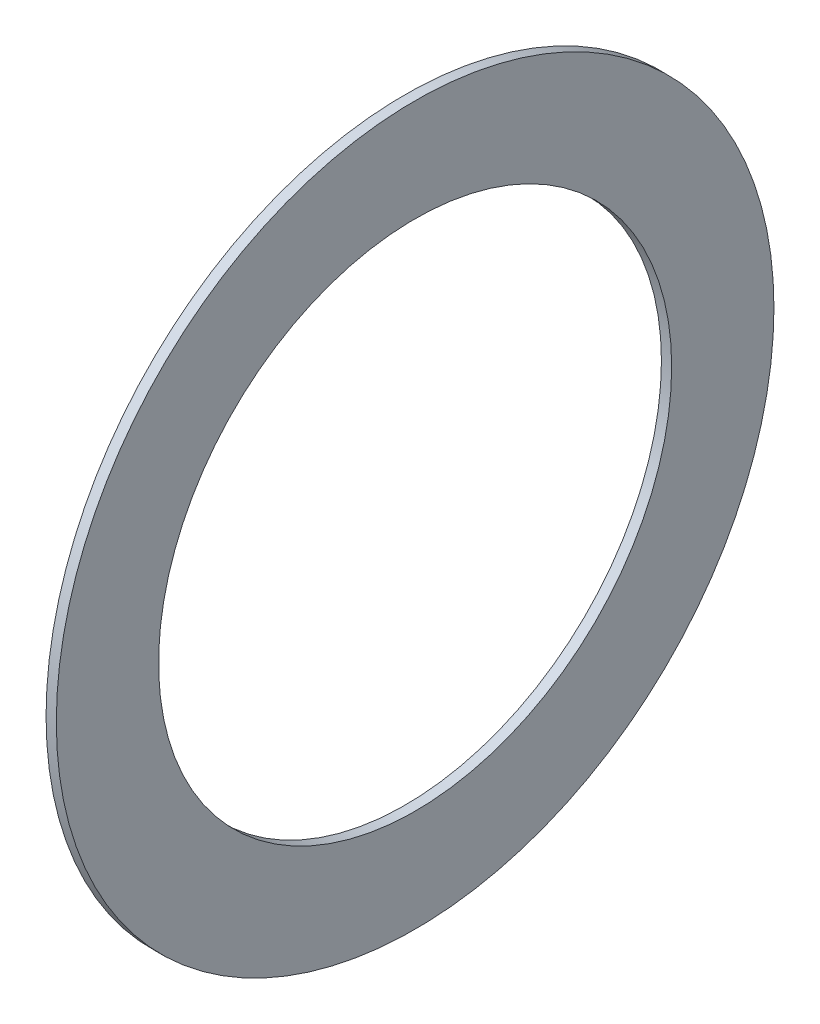
from build123d import *

# Parameters (mm, degrees)
SKETCH3_R                = 35
SKETCH3_R_2              = 25.025
BOSS_EXTRUDE1_DEPTH      = 0.5
BOSS_EXTRUDE1_DEPTH_BACK = 0.5


with BuildPart() as part:
    # Sketch3 → Boss-Extrude1 (new body, two sides)
    with BuildSketch(Plane(origin=(0, 0, 0), x_dir=(0, 0, -1), z_dir=(1, 0, 0))) as boss_extrude1_sk:
        Circle(SKETCH3_R)
        Circle(SKETCH3_R_2, mode=Mode.SUBTRACT)
    extrude(amount=BOSS_EXTRUDE1_DEPTH)
    extrude(boss_extrude1_sk.sketch, amount=-BOSS_EXTRUDE1_DEPTH_BACK)


solid = part.part
